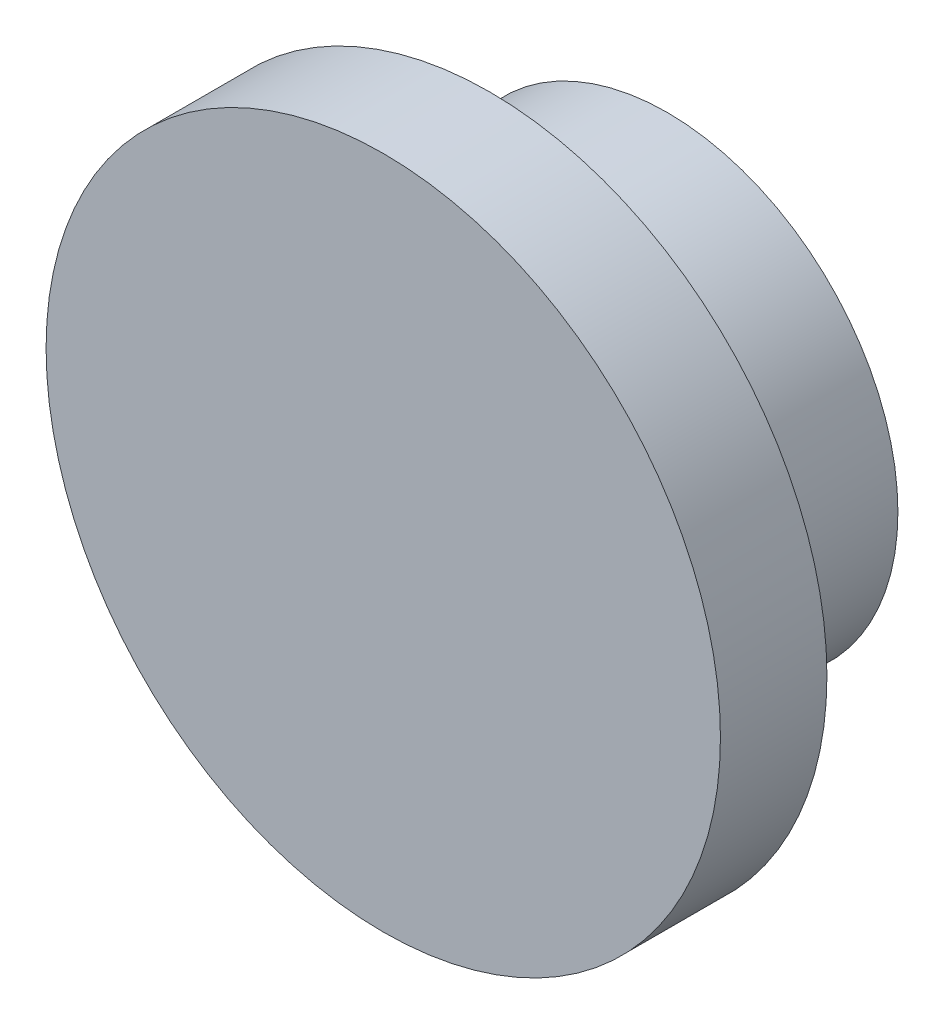
from build123d import *


with BuildPart() as part:
    # Sketch1 → Revolve1 (revolve)
    with BuildSketch(Plane(origin=(0, 0, 0), x_dir=(0, 0, -1), z_dir=(1, 0, 0))):
        Polygon((0, 0), (0, 2.413), (0.762, 2.413), (0.762, 1.651), (2.032, 1.651), (2.032, 0), align=None)
    revolve(axis=Axis((0, 0, -2.032), (0, 0, 1)))


solid = part.part
